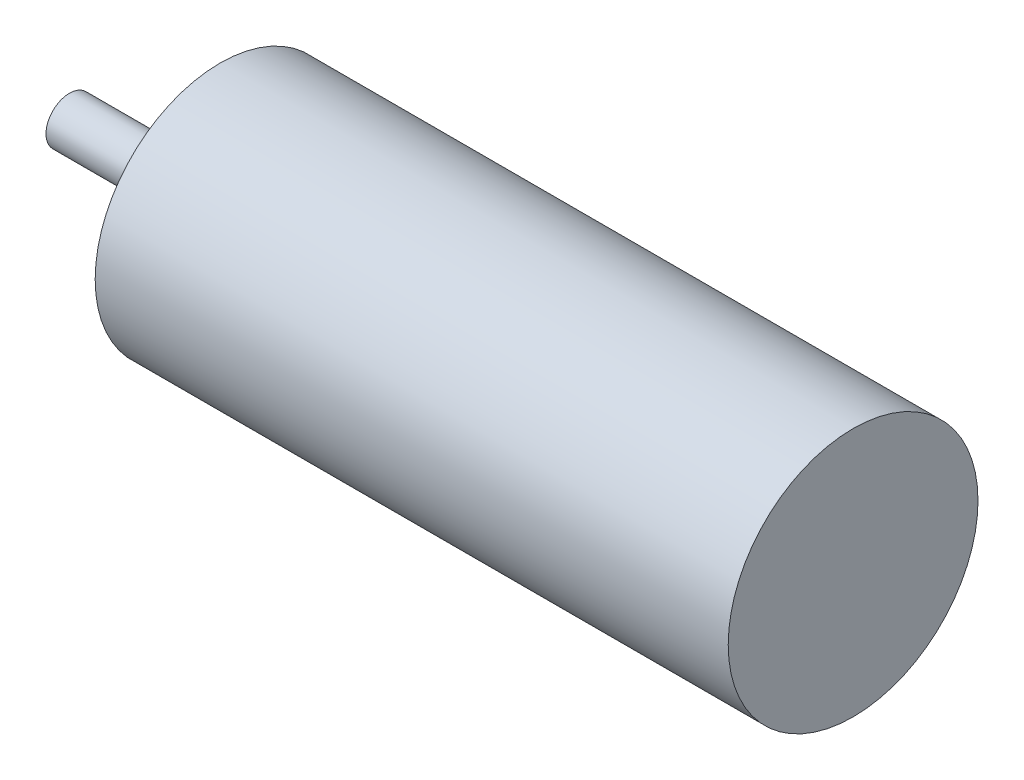
from build123d import *

# Parameters (mm, degrees)
SKETCH2_R          = 1.5
CUT_EXTRUDE1_DEPTH = 5


with BuildPart() as part:
    # Sketch1 → Revolve1 (revolve)
    with BuildSketch(Plane.XY):
        Polygon((0, 0), (100.4, 0), (100.4, 16), (19.3, 16), (19.3, 9), (15.5, 9), (15.5, 3), (0, 3), align=None)
    revolve(axis=Axis((0, 0, 0), (1, 0, 0)))

    # Sketch2 → Cut-Extrude1 (cut)
    with BuildSketch(Plane.ZY.offset(-19.3)):
        with Locations((0, 13)):
            Circle(SKETCH2_R)
        with Locations((0, -13)):
            Circle(SKETCH2_R)
        with Locations((-13, 0)):
            Circle(SKETCH2_R)
        with Locations((13, 0)):
            Circle(SKETCH2_R)
    extrude(amount=-CUT_EXTRUDE1_DEPTH, mode=Mode.SUBTRACT)


solid = part.part
